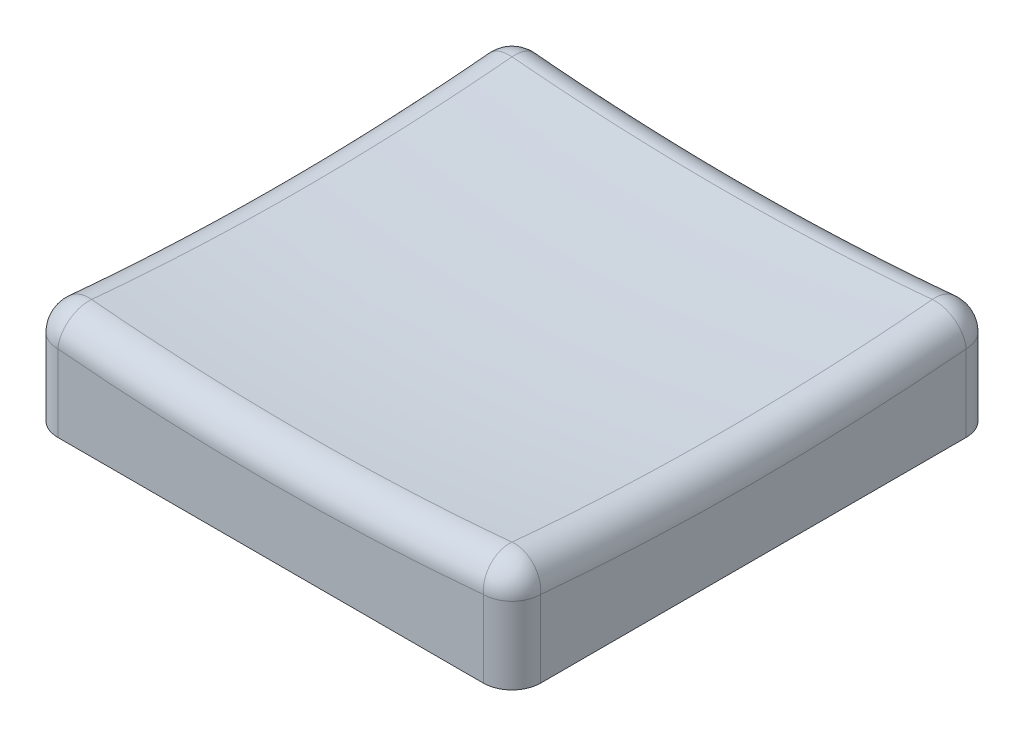
from build123d import *

# Parameters (mm, degrees)
SKETCH_1_W      = 16.85
SKETCH_1_H      = 16.85
EXTRUDE_1_DEPTH = 4
SHELL_1_T       = -1.5
FILLET_1_R      = 1


with BuildPart() as part:
    # 草图1 → 凸台-拉伸1 (new body)
    with BuildSketch(Plane(origin=(0, 0, 0), x_dir=(1, 0, 0), z_dir=(0, 1, 0))):
        Rectangle(SKETCH_1_W, SKETCH_1_H)
    extrude(amount=EXTRUDE_1_DEPTH)

    # 抽壳1
    shell_1_openings = [part.faces().sort_by_distance(p)[0] for p in [
        (0, 0, 0),
    ]]
    offset(amount=SHELL_1_T, openings=shell_1_openings, kind=Kind.INTERSECTION)

    # 草图2 → 切除-旋转5 (revolve, cut)
    with BuildSketch(Plane.XY):
        with BuildLine():
            Line((0, 164), (0, 3))
            ThreePointArc((0, 3), (80.5, 83.5), (0, 164))
        make_face()
    revolve(axis=Axis((0, 0, 0), (0, 1, 0)), mode=Mode.SUBTRACT)

    # 圆角1
    fillet_1_edges = [part.edges().sort_by_distance(p)[0] for p in [
        (8.425, 1.943314789, 8.425),
        (-8.425, 1.943314789, 8.425),
        (0, 3.442087368, 8.425),
        (-8.425, 1.943314789, -8.425),
        (8.425, 1.943314789, -8.425),
        (0, 3.442087368, -8.425),
        (8.425, 3.553300166, 4.218359953),
        (-8.425, 3.442087368, 0),
    ]]
    fillet(fillet_1_edges, radius=FILLET_1_R)


solid = part.part
